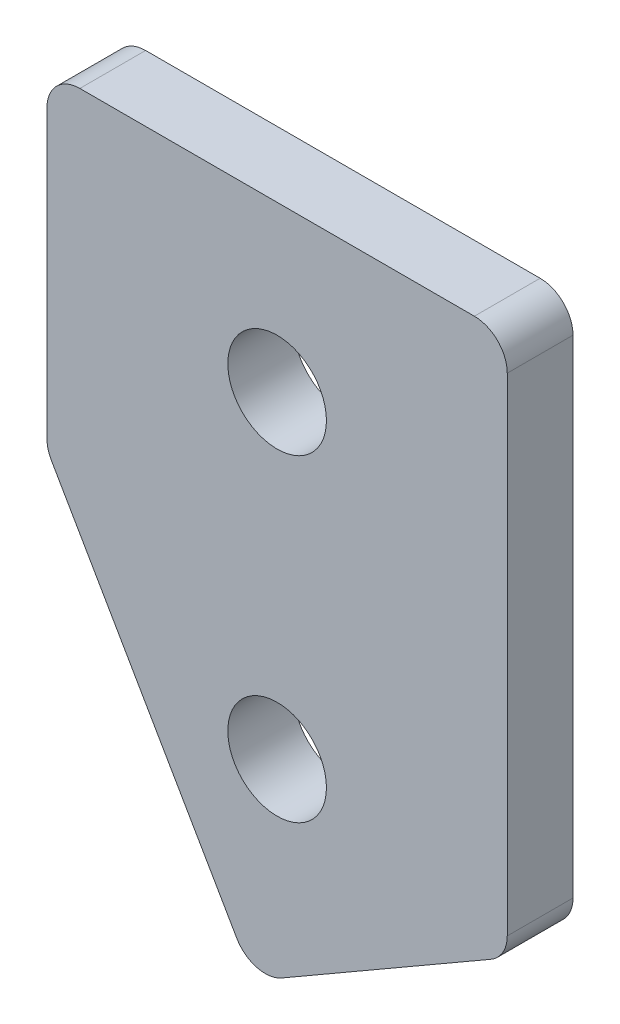
from build123d import *

# Parameters (mm, degrees)
SKETCH_1_R      = 1.5
EXTRUDE_1_DEPTH = 2
FILLET_1_R      = 1


with BuildPart() as part:
    # 草图1 → 凸台-拉伸1 (new body)
    with BuildSketch(Plane.XY):
        Polygon((0, 10), (14, 10), (14, -6.402050808), (6.272169318, -10.863715932), (0, 0), align=None)
        with Locations((7, 5)):
            Circle(SKETCH_1_R, mode=Mode.SUBTRACT)
        with Locations((7, -4.67)):
            Circle(SKETCH_1_R, mode=Mode.SUBTRACT)
    extrude(amount=EXTRUDE_1_DEPTH)

    # 圆角1
    fillet_1_edges = [part.edges().sort_by_distance(p)[0] for p in [
        (0, 10, 1),
        (14, 10, 1),
        (14, -6.402050808, 1),
        (6.272169318, -10.863715932, 1),
        (0, 0, 1),
    ]]
    fillet(fillet_1_edges, radius=FILLET_1_R)


solid = part.part
